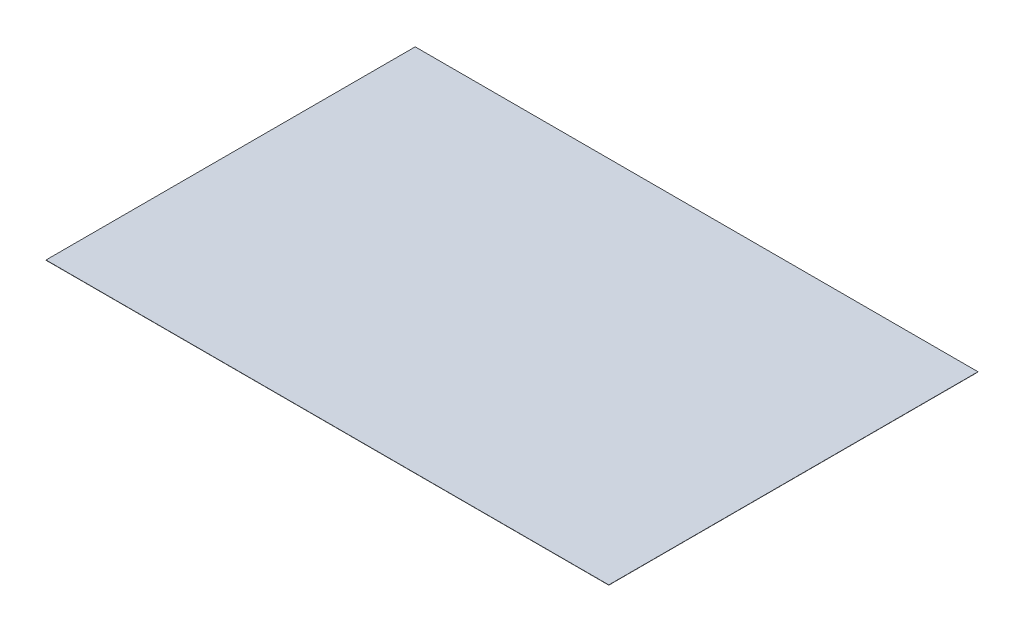
from build123d import *

# Parameters (mm, degrees)
ESQUISSE1_W        = 500
ESQUISSE1_H        = 328
BOSS_EXTRU_1_DEPTH = 0.2


with BuildPart() as part:
    # Esquisse1 → Boss.-Extru.1 (new body)
    with BuildSketch(Plane(origin=(0, 0, 0), x_dir=(1, 0, 0), z_dir=(0, 1, 0))):
        Rectangle(ESQUISSE1_W, ESQUISSE1_H)
    extrude(amount=BOSS_EXTRU_1_DEPTH)


solid = part.part
